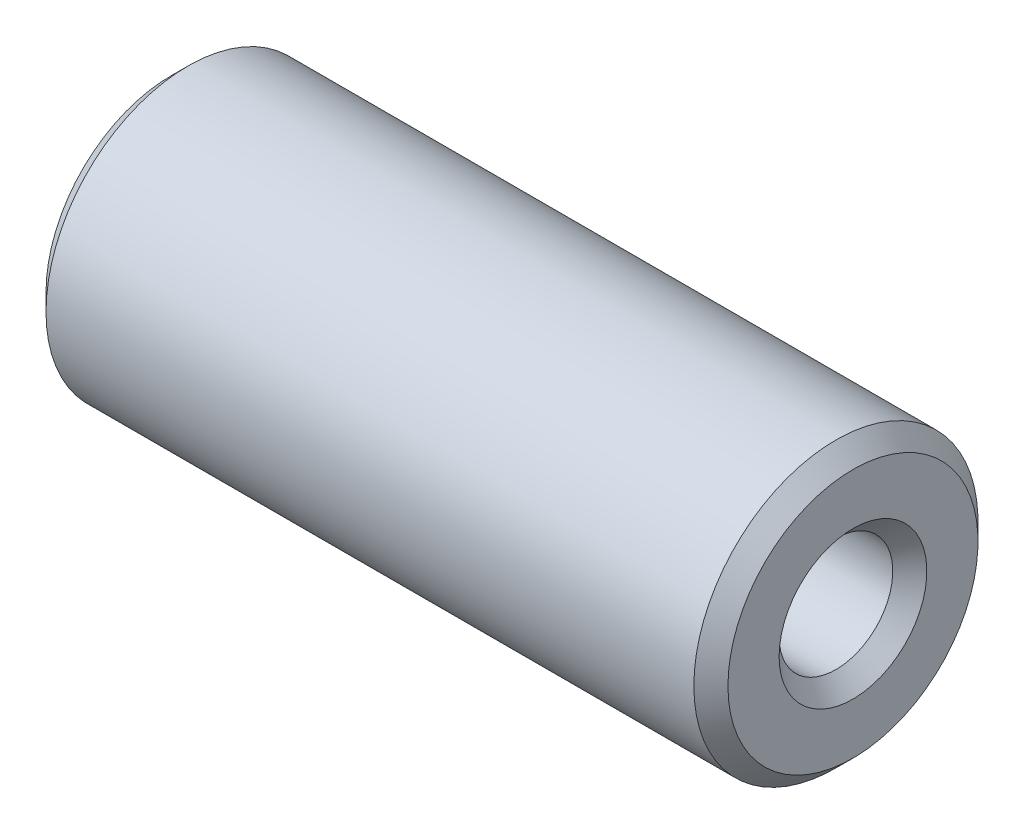
from build123d import *


with BuildPart() as part:
    # Esquisse1 → Base-Révolution (revolve)
    with BuildSketch(Plane.XY, mode=Mode.PRIVATE) as base_r_volution_sk:
        Polygon((0, 1.3), (0, 2.2), (0.3, 2.5), (11.7, 2.5), (12, 2.2), (12, 1.3), (11.7, 1), (0.3, 1), align=None)
    revolve(base_r_volution_sk.sketch.rotate(Axis((0, 0, 0), (1, 0, 0)), 90), axis=Axis((0, 0, 0), (1, 0, 0)))  # turned: the seam where the file's is


solid = part.part
